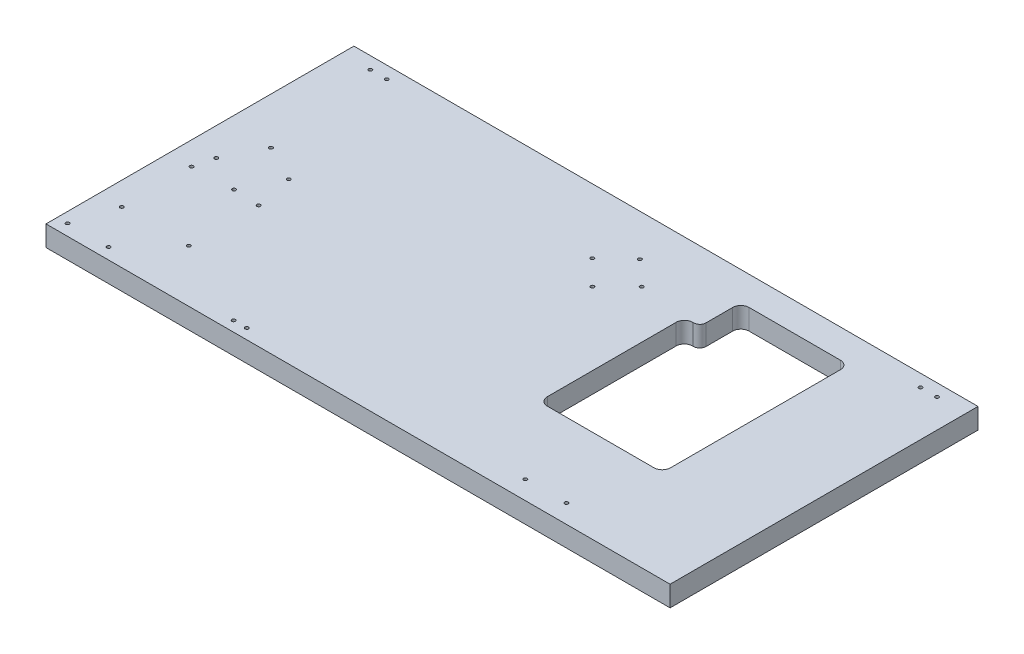
from build123d import *

# Parameters (mm, degrees)
SKIZZE3_W                       = 1520
SKIZZE3_H                       = 750
AUFSATZ_LINEAR_AUSTRAGEN1_DEPTH = 50
M10_GEWINDEBOHRUNG1_D           = 8.5


with BuildPart() as part:
    # Skizze3 → Aufsatz-Linear austragen1 (new body)
    with BuildSketch(Plane(origin=(0, 0, 0), x_dir=(1, 0, 0), z_dir=(0, 1, 0))):
        with Locations((760, -375)):
            Rectangle(SKIZZE3_W, SKIZZE3_H)
        with BuildLine():
            Line((995, -170), (997.5, -170))
            ThreePointArc((997.5, -170), (1008.106601718, -165.606601718), (1012.5, -155))
            Line((1012.5, -155), (1012.5, -90))
            ThreePointArc((1012.5, -90), (1018.357864376, -75.857864376), (1032.5, -70))
            Line((1032.5, -70), (1255, -70))
            ThreePointArc((1255, -70), (1269.142135624, -75.857864376), (1275, -90))
            Line((1275, -90), (1275, -504))
            ThreePointArc((1275, -504), (1269.142135624, -518.142135624), (1255, -524))
            Line((1255, -524), (995, -524))
            ThreePointArc((995, -524), (980.857864376, -518.142135624), (975, -504))
            Line((975, -504), (975, -190))
            ThreePointArc((975, -190), (980.857864376, -175.857864376), (995, -170))
        make_face(mode=Mode.SUBTRACT)
    extrude(amount=AUFSATZ_LINEAR_AUSTRAGEN1_DEPTH)

    # M10 Gewindebohrung1 (through all)
    with Locations(Plane(origin=(0, 0, 0), x_dir=(-1, 0, 0), z_dir=(0, -1, 0))):
        with Locations((-70, -30), (-110, -30), (-432, -725), (-464, -725), (-125, -722.5), (-25, -722.5), (-56.5, -622), (-56.5, -452), (-220, -452), (-220, -622), (-68.426043859, -403.631189606), (-1122.5, -705), (-1222.5, -705), (-1410, -30), (-1450, -30), (-113.368810394, -315.426043859), (-201.573956141, -360.368810394), (-156.631189606, -448.573956141), (-797.85367918, -217), (-797.85367918, -101.25), (-857.85367918, -157), (-737.85367918, -157)):
            Hole(M10_GEWINDEBOHRUNG1_D / 2)


solid = part.part
